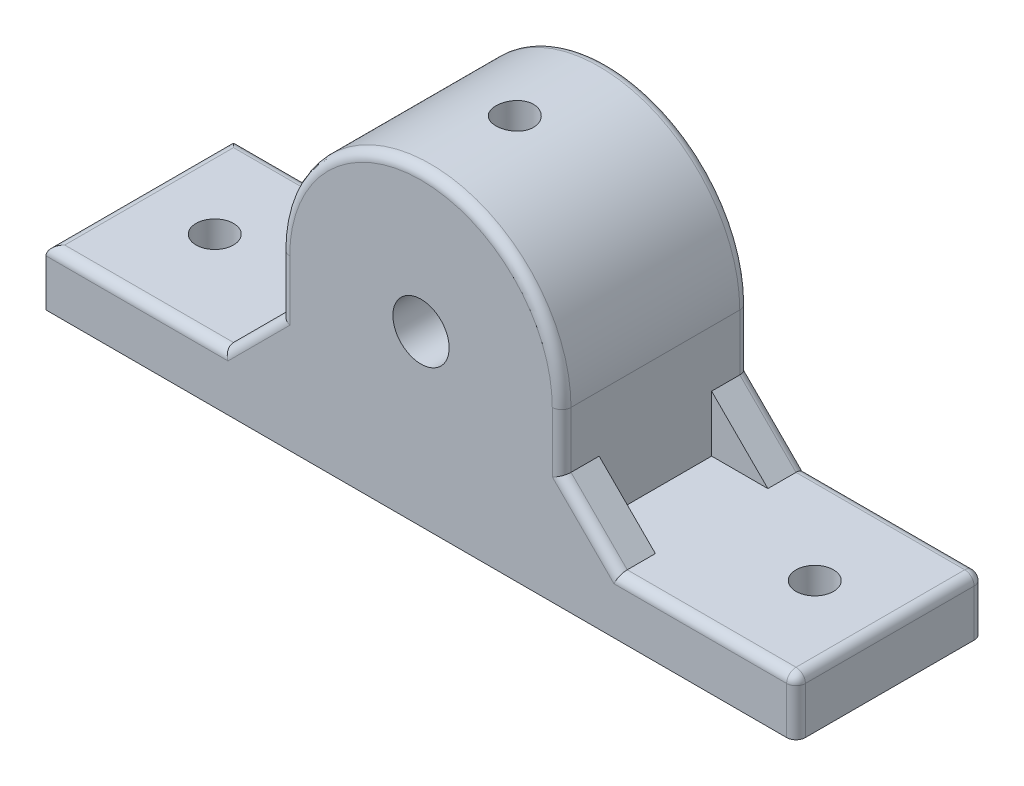
from build123d import *

# Parameters (mm, degrees)
BOSS_EXTRU_1_DEPTH           = 5
BOSS_EXTRU_2_DEPTH           = 2
SYM_TRIE2_COPY_1_DEPTH       = 2
CONG_1_R                     = 0.5
ESQUISSE4_R                  = 1.5
ENL_V_MAT_EXTRU_2_DEPTH      = 1.0000001
ENL_V_MAT_EXTRU_2_DEPTH_BACK = 11.0000001
ESQUISSE5_R                  = 1
ENL_V_MAT_EXTRU_3_DEPTH      = 7
ESQUISSE3_R                  = 1
ENL_V_MAT_EXTRU_1_DEPTH      = 14.500000115
ENL_V_MAT_EXTRU_1_DEPTH_BACK = 4


with BuildPart() as part:
    # Esquisse1 → Boss.-Extru.1 (new body, symmetric)
    with BuildSketch(Plane.XY):
        with BuildLine():
            Line((-20, 0), (20, 0))
            Line((20, 0), (20, 3))
            Line((20, 3), (7.5, 3))
            Line((7.5, 3), (7.5, 9))
            ThreePointArc((7.5, 9), (0, 16.5), (-7.5, 9))
            Line((-7.5, 9), (-7.5, 3))
            Line((-7.5, 3), (-20, 3))
            Line((-20, 3), (-20, 0))
        make_face()
    extrude(amount=BOSS_EXTRU_1_DEPTH, both=True)

    # Esquisse2 → Boss.-Extru.2 (add)
    with BuildSketch(Plane.XY.offset(5)):
        Polygon((-10.5, 3), (-7.5, 6), (-7.5, 3), align=None)
    boss_extru_2 = extrude(amount=-BOSS_EXTRU_2_DEPTH)

    # Symétrie1: Boss.-Extru.2 across plane
    add(boss_extru_2.mirror(Plane.XY))

    # Symétrie2: Boss.-Extru.2 across plane
    add(boss_extru_2.mirror(Plane(origin=(0, 0, 0), x_dir=(0, 0, 1), z_dir=(1, 0, 0))))

    # Symétrie2 copy 1 sketch → Symétrie2 copy 1 (add)
    with BuildSketch(Plane(origin=(0, 0, -5), x_dir=(-1, 0, 0), z_dir=(0, 0, -1))):
        Polygon((-10.5, 3), (-7.5, 6), (-7.5, 3), align=None)
    extrude(amount=-SYM_TRIE2_COPY_1_DEPTH)

    # Congé1
    cong_1_edges = [part.edges().sort_by_distance(p)[0] for p in [
        (20, 1.5, 5),
        (15.25, 3, 5),
        (-20, 3, 0),
        (20, 3, 0),
        (0, 16.5, 5),
        (-7.5, 7.5, 5),
        (-15.25, 3, 5),
        (-9, 4.5, 5),
        (-15.25, 3, -5),
        (-9, 4.5, -5),
        (7.5, 7.5, -5),
        (9, 4.5, -5),
        (7.5, 7.5, 5),
        (9, 4.5, 5),
        (-7.5, 7.5, -5),
        (0, 16.5, -5),
        (15.25, 3, -5),
        (20, 1.5, -5),
    ]]
    fillet(cong_1_edges, radius=CONG_1_R)

    # Esquisse4 → Enlèv. mat.-Extru.2 (cut, two sides)
    with BuildSketch(Plane.XY.offset(5)) as enl_v_mat_extru_2_sk:
        with Locations((0, 9)):
            Circle(ESQUISSE4_R)
    extrude(amount=ENL_V_MAT_EXTRU_2_DEPTH, mode=Mode.SUBTRACT)
    extrude(enl_v_mat_extru_2_sk.sketch, amount=-ENL_V_MAT_EXTRU_2_DEPTH_BACK, mode=Mode.SUBTRACT)

    # Esquisse5 → Enlèv. mat.-Extru.3 (cut)
    with BuildSketch(Plane(origin=(0, 16.5, 0), x_dir=(1, 0, 0), z_dir=(0, 1, 0))):
        Circle(ESQUISSE5_R)
    extrude(amount=-ENL_V_MAT_EXTRU_3_DEPTH, mode=Mode.SUBTRACT)

    # Esquisse3 → Enlèv. mat.-Extru.1 (cut, two sides)
    with BuildSketch(Plane(origin=(0, 3, 0), x_dir=(1, 0, 0), z_dir=(0, 1, 0))) as enl_v_mat_extru_1_sk:
        with Locations((-16, 0)):
            Circle(ESQUISSE3_R)
        with Locations((16, 0)):
            Circle(ESQUISSE3_R)
    extrude(amount=ENL_V_MAT_EXTRU_1_DEPTH, mode=Mode.SUBTRACT)
    extrude(enl_v_mat_extru_1_sk.sketch, amount=-ENL_V_MAT_EXTRU_1_DEPTH_BACK, mode=Mode.SUBTRACT)


solid = part.part
